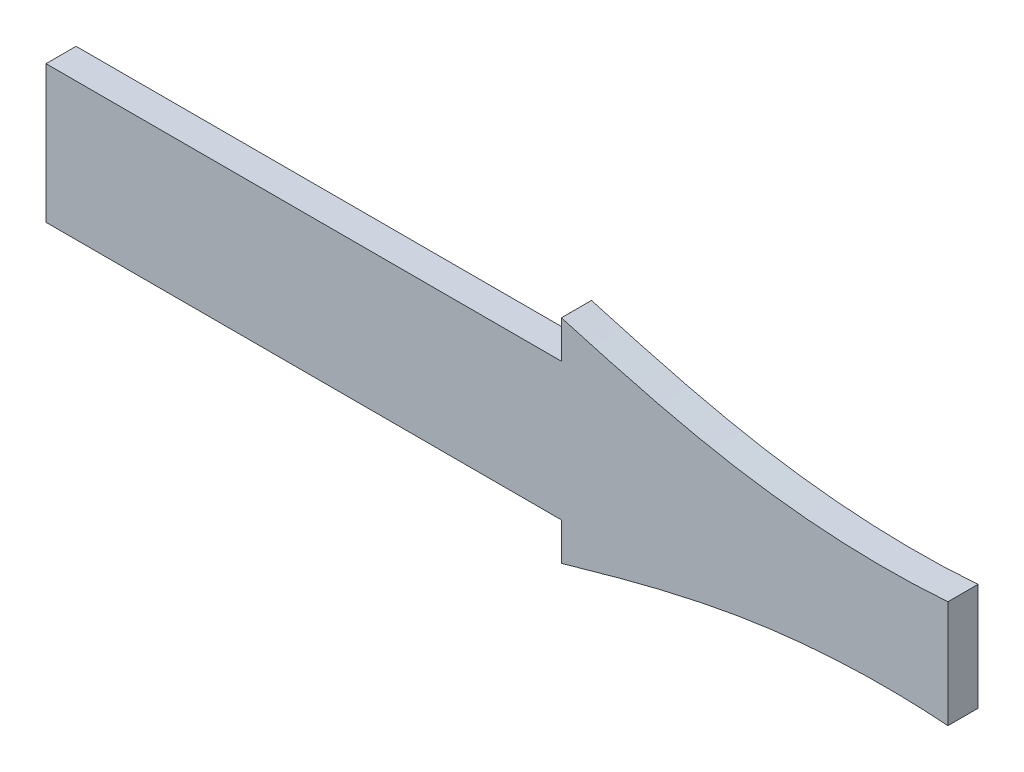
from build123d import *

# Parameters (mm, degrees)
BOSS_EXTRUDE1_DEPTH = 4


with BuildPart() as part:
    # Sketch2 → Boss-Extrude1 (new body)
    with BuildSketch(Plane.XY):
        with BuildLine():
            Line((262.480297025, 7.13882444), (262.480297025, -7.13882444))
            add(Edge.make_bspline(
                [(211.080761054, -14.13724363), (211.917848379, -13.89687615), (219.460294723, -11.745335639), (236.298901932, -7.327257032), (252.970465499, -6.414227327), (262.480297025, -7.13882444)],
                knots=[0.460880267, 0.460880267, 0.460880267, 0.460880267, 0.487879211, 0.704009033, 1, 1, 1, 1], degree=3))
            Line((211.080761054, -14.13724363), (211.080761054, -9.13724363))
            Line((211.080761054, -9.13724363), (142.548046426, -9.13724363))
            Line((142.548046426, -9.13724363), (142.548046426, 9.13724363))
            Line((142.548046426, 9.13724363), (211.080761054, 9.13724363))
            Line((211.080761054, 9.13724363), (211.080761054, 14.13724363))
            add(Edge.make_bspline(
                [(211.080761054, 14.13724363), (211.917848379, 13.89687615), (219.460294722, 11.745335639), (236.298901932, 7.327257032), (252.970465499, 6.414227327), (262.480297025, 7.13882444)],
                knots=[0.460880267, 0.460880267, 0.460880267, 0.460880267, 0.487879211, 0.704009033, 1, 1, 1, 1], degree=3))
        make_face()
    extrude(amount=BOSS_EXTRUDE1_DEPTH)


solid = part.part
